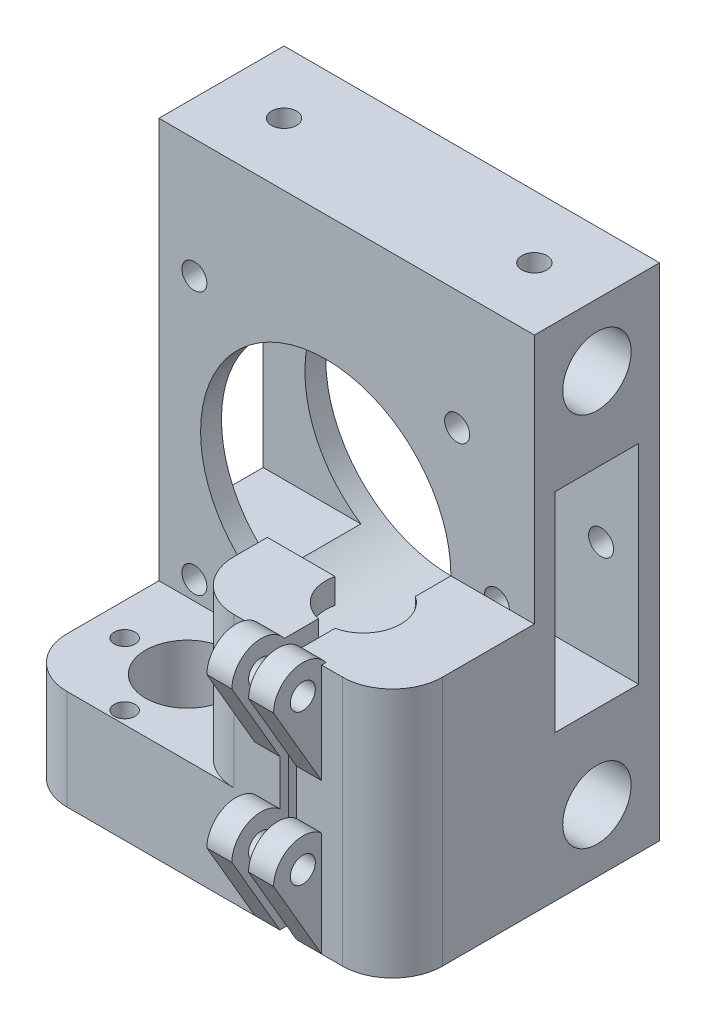
from build123d import *

# Parameters (mm, degrees)
SKETCH1_W           = 45
SKETCH1_H           = 60
BOSS_EXTRUDE1_DEPTH = 15
SKETCH2_R           = 4.1
SKETCH2_W           = 10
SKETCH2_H           = 25
CUT_EXTRUDE1_DEPTH  = 46
SKETCH3_W           = 17
SKETCH3_H           = 12
BOSS_EXTRUDE2_DEPTH = 45
SKETCH4_W           = 25
SKETCH4_H           = 17
BOSS_EXTRUDE3_DEPTH = 18
SKETCH5_W           = 2
SKETCH5_H           = 30
CUT_EXTRUDE2_DEPTH  = 5
SKETCH6_R           = 4.5
CUT_EXTRUDE3_DEPTH  = 61
SKETCH7_R           = 8
SKETCH7_R_2         = 5
SKETCH7_R_3         = 1.25
CUT_EXTRUDE4_DEPTH  = 27
SKETCH8_R           = 15
SKETCH8_R_2         = 1.5
CUT_EXTRUDE5_DEPTH  = 22
FILLET1_R           = 6
SKETCH9_R           = 1.5
CUT_EXTRUDE6_DEPTH  = 15
SKETCH10_R          = 1.5
CUT_EXTRUDE7_DEPTH  = 5
CUT_EXTRUDE8_START  = -60
SKETCH10_2_R        = 1.5
CUT_EXTRUDE8_DEPTH  = 5
SKETCH12_R          = 1.5
BOSS_EXTRUDE4_DEPTH = 3
BOSS_EXTRUDE5_START = 2
SKETCH12_3_R        = 1.5
BOSS_EXTRUDE5_DEPTH = 3


with BuildPart() as part:
    # Sketch1 → Boss-Extrude1 (new body)
    with BuildSketch(Plane.XY):
        Rectangle(SKETCH1_W, SKETCH1_H)
    extrude(amount=BOSS_EXTRUDE1_DEPTH)

    # Sketch2 → Cut-Extrude1 (cut, through all)
    with BuildSketch(Plane(origin=(22.5, 0, 0), x_dir=(0, 0, -1), z_dir=(1, 0, 0))):
        with Locations((-7.5, 22.5)):
            Circle(SKETCH2_R)
        with Locations((-7.5, -22.5)):
            Circle(SKETCH2_R)
        with Locations((-7.5, 0)):
            Rectangle(SKETCH2_W, SKETCH2_H)
    extrude(amount=-CUT_EXTRUDE1_DEPTH, mode=Mode.SUBTRACT)

    # Sketch3 → Boss-Extrude2 (add)
    with BuildSketch(Plane.ZY.offset(22.5)):
        with Locations((23.5, -24)):
            Rectangle(SKETCH3_W, SKETCH3_H)
    extrude(amount=-BOSS_EXTRUDE2_DEPTH)

    # Sketch4 → Boss-Extrude3 (add)
    with BuildSketch(Plane(origin=(0, -18, 0), x_dir=(1, 0, 0), z_dir=(0, 1, 0))):
        with Locations((10, -23.5)):
            Rectangle(SKETCH4_W, SKETCH4_H)
    extrude(amount=BOSS_EXTRUDE3_DEPTH)

    # Sketch5 → Cut-Extrude2 (cut)
    with BuildSketch(Plane.XY.offset(32)):
        with Locations((10, -15)):
            Rectangle(SKETCH5_W, SKETCH5_H)
    extrude(amount=-CUT_EXTRUDE2_DEPTH, mode=Mode.SUBTRACT)

    # Sketch6 → Cut-Extrude3 (cut, through all)
    with BuildSketch(Plane.XZ.offset(30)):
        with Locations((10, 23)):
            Circle(SKETCH6_R)
    extrude(amount=-CUT_EXTRUDE3_DEPTH, mode=Mode.SUBTRACT)

    # Sketch7 → Cut-Extrude4 (cut)
    with BuildSketch(Plane.XZ.offset(30)):
        with Locations((10, 23)):
            Circle(SKETCH7_R)
        with Locations((-11.1, 23)):
            Circle(SKETCH7_R_2)
        with Locations((-3.6, 23)):
            Circle(SKETCH7_R_3)
        with Locations((-11.1, 30.5)):
            Circle(SKETCH7_R_3)
        with Locations((-11.1, 15.5)):
            Circle(SKETCH7_R_3)
        with Locations((-18.6, 23)):
            Circle(SKETCH7_R_3)
    extrude(amount=-CUT_EXTRUDE4_DEPTH, mode=Mode.SUBTRACT)

    # Sketch8 → Cut-Extrude5 (cut)
    with BuildSketch(Plane(origin=(0, 0, 0), x_dir=(-1, 0, 0), z_dir=(0, 0, -1))):
        with Locations((2.5, 0)):
            Circle(SKETCH8_R)
        with Locations((18.25, 15.75)):
            Circle(SKETCH8_R_2)
        with Locations((-13.25, 15.75)):
            Circle(SKETCH8_R_2)
        with Locations((-13.25, -15.75)):
            Circle(SKETCH8_R_2)
        with Locations((18.25, -15.75)):
            Circle(SKETCH8_R_2)
    extrude(amount=-CUT_EXTRUDE5_DEPTH, mode=Mode.SUBTRACT)

    # Fillet1
    fillet1_edges = [part.edges().sort_by_distance(p)[0] for p in [
        (-22.5, -24, 32),
        (-2.5, -9, 32),
        (22.5, -15, 32),
    ]]
    fillet(fillet1_edges, radius=FILLET1_R)

    # Sketch9 → Cut-Extrude6 (cut)
    with BuildSketch(Plane(origin=(0, 0, 0), x_dir=(-1, 0, 0), z_dir=(0, 0, -1))):
        with Locations((-18, 0)):
            Circle(SKETCH9_R)
    extrude(amount=-CUT_EXTRUDE6_DEPTH, mode=Mode.SUBTRACT)

    # Sketch10 → Cut-Extrude7 (cut)
    with BuildSketch(Plane(origin=(0, 30, 0), x_dir=(1, 0, 0), z_dir=(0, 1, 0))):
        with Locations((-15, -7.5)):
            Circle(SKETCH10_R)
        with Locations((15, -7.5)):
            Circle(SKETCH10_R)
    extrude(amount=-CUT_EXTRUDE7_DEPTH, mode=Mode.SUBTRACT)

    # Sketch10_2 → Cut-Extrude8 (cut)
    with BuildSketch(Plane(origin=(0, 30, 0), x_dir=(1, 0, 0), z_dir=(0, 1, 0)).offset(CUT_EXTRUDE8_START)):
        with Locations((-15, -7.5)):
            Circle(SKETCH10_2_R)
        with Locations((15, -7.5)):
            Circle(SKETCH10_2_R)
    extrude(amount=CUT_EXTRUDE8_DEPTH, mode=Mode.SUBTRACT)

    # Sketch12 → Boss-Extrude4 (add)
    with BuildSketch(Plane(origin=(9, 0, 0), x_dir=(0, 0, -1), z_dir=(1, 0, 0))):
        with BuildLine():
            Line((-32, -30), (-37.75, -20.113140033))
            ThreePointArc((-37.75, -20.113140033), (-34.822445965, -16.660270847), (-30.937253933, -18.983665157))
            Line((-30.937253933, -18.983665157), (-30.937253933, -30))
            Line((-30.937253933, -30), (-32, -30))
        make_face()
        with Locations((-34.25, -20.113140033)):
            Circle(SKETCH12_R, mode=Mode.SUBTRACT)
        with BuildLine():
            Line((-32, -12), (-37.75, -2.113140033))
            ThreePointArc((-37.75, -2.113140033), (-34.822445965, 1.339729153), (-30.937253933, -0.983665157))
            Line((-30.937253933, -0.983665157), (-30.937253933, -12))
            Line((-30.937253933, -12), (-32, -12))
        make_face()
        with Locations((-34.25, -2.113140033)):
            Circle(SKETCH12_R, mode=Mode.SUBTRACT)
    extrude(amount=-BOSS_EXTRUDE4_DEPTH)

    # Sketch12_3 → Boss-Extrude5 (add)
    with BuildSketch(Plane(origin=(9, 0, 0), x_dir=(0, 0, -1), z_dir=(1, 0, 0)).offset(BOSS_EXTRUDE5_START)):
        with BuildLine():
            Line((-32, -30), (-37.75, -20.113140033))
            ThreePointArc((-37.75, -20.113140033), (-34.822445965, -16.660270847), (-30.937253933, -18.983665157))
            Line((-30.937253933, -18.983665157), (-30.937253933, -30))
            Line((-30.937253933, -30), (-32, -30))
        make_face()
        with Locations((-34.25, -20.113140033)):
            Circle(SKETCH12_3_R, mode=Mode.SUBTRACT)
        with BuildLine():
            Line((-32, -12), (-37.75, -2.113140033))
            ThreePointArc((-37.75, -2.113140033), (-34.822445965, 1.339729153), (-30.937253933, -0.983665157))
            Line((-30.937253933, -0.983665157), (-30.937253933, -12))
            Line((-30.937253933, -12), (-32, -12))
        make_face()
        with Locations((-34.25, -2.113140033)):
            Circle(SKETCH12_3_R, mode=Mode.SUBTRACT)
    extrude(amount=BOSS_EXTRUDE5_DEPTH)


solid = part.part
